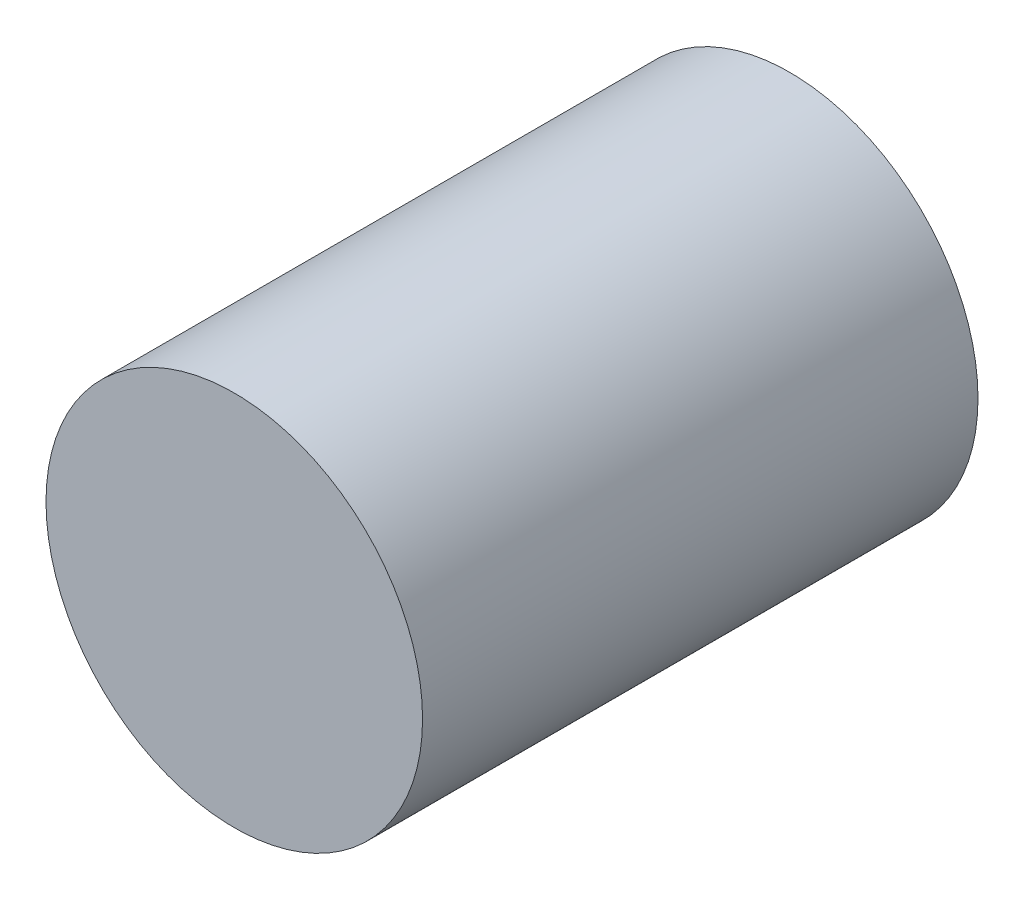
from build123d import *

# Parameters (mm, degrees)
SKETCH1_R           = 30.507602491
BOSS_EXTRUDE1_DEPTH = 90


with BuildPart() as part:
    # Sketch1 → Boss-Extrude1 (new body)
    with BuildSketch(Plane.XY):
        Circle(SKETCH1_R)
    extrude(amount=BOSS_EXTRUDE1_DEPTH)


solid = part.part
